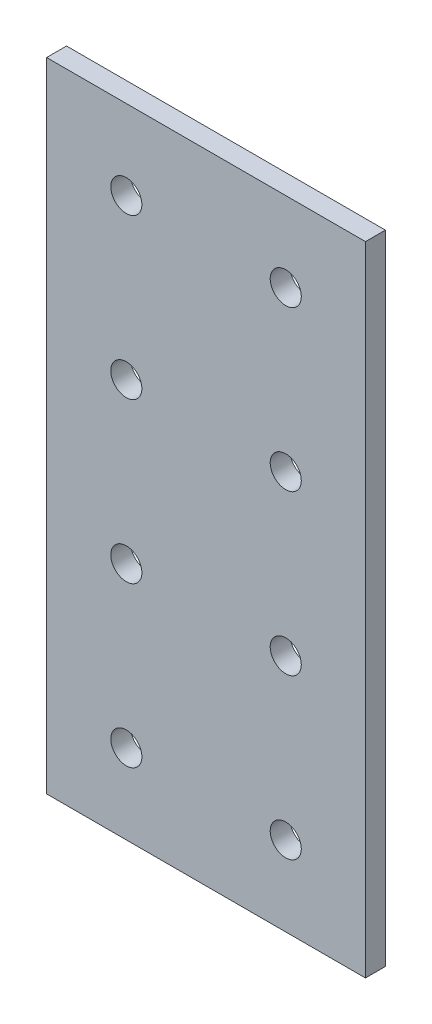
from build123d import *

# Parameters (mm, degrees)
SKETCH1_R           = 2.4765
BOSS_EXTRUDE1_DEPTH = 3.175


with BuildPart() as part:
    # Sketch1 → Boss-Extrude1 (new body)
    with BuildSketch(Plane.XY):
        Polygon((0, 0), (25.4, 0), (25.4, 50.8), (25.4, 101.6), (-25.4, 101.6), (-25.4, 50.8), (-25.4, 0), align=None)
        with Locations((12.7, 88.9)):
            Circle(SKETCH1_R, mode=Mode.SUBTRACT)
        with Locations((-12.7, 88.9)):
            Circle(SKETCH1_R, mode=Mode.SUBTRACT)
        with Locations((-12.7, 63.5)):
            Circle(SKETCH1_R, mode=Mode.SUBTRACT)
        with Locations((12.7, 63.5)):
            Circle(SKETCH1_R, mode=Mode.SUBTRACT)
        with Locations((12.7, 12.7)):
            Circle(SKETCH1_R, mode=Mode.SUBTRACT)
        with Locations((-12.7, 12.7)):
            Circle(SKETCH1_R, mode=Mode.SUBTRACT)
        with Locations((-12.7, 38.1)):
            Circle(SKETCH1_R, mode=Mode.SUBTRACT)
        with Locations((12.7, 38.1)):
            Circle(SKETCH1_R, mode=Mode.SUBTRACT)
    extrude(amount=BOSS_EXTRUDE1_DEPTH)


solid = part.part
